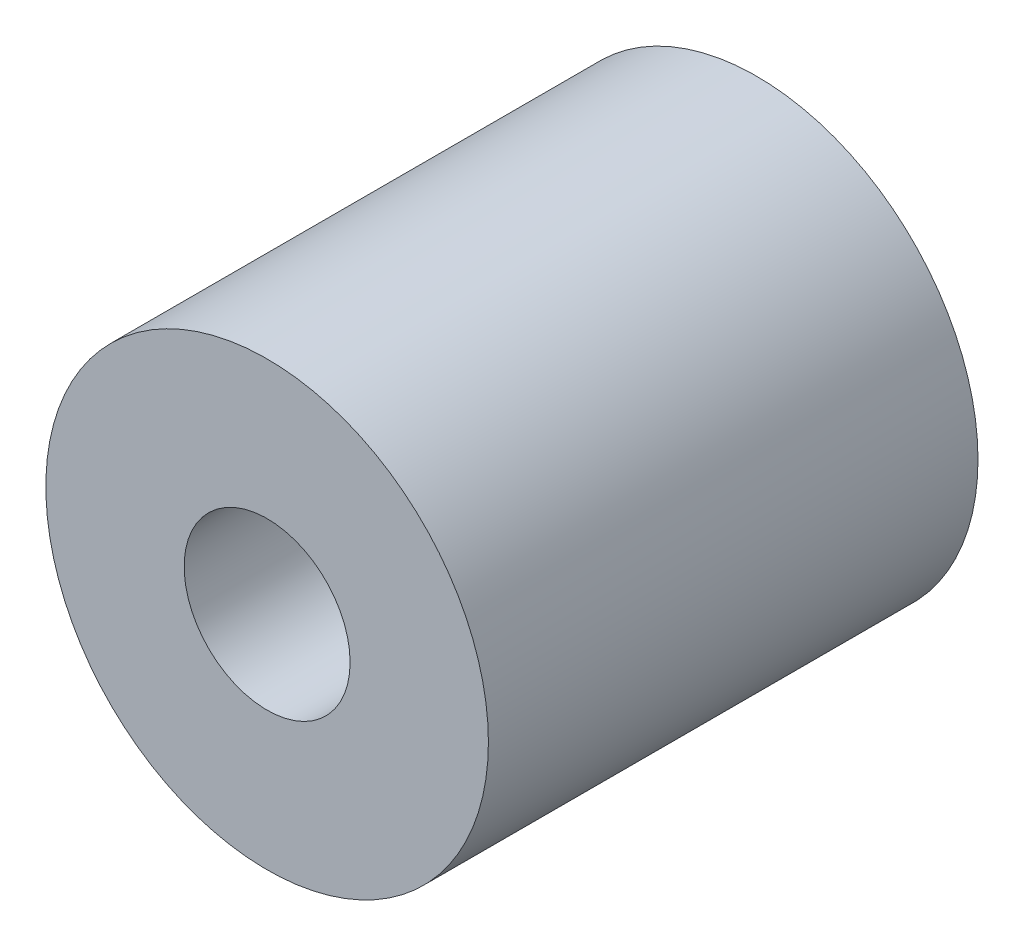
from build123d import *

# Parameters (mm, degrees)
CROQUIS1_R              = 16
CROQUIS1_R_2            = 11
SALIENTE_EXTRUIR1_DEPTH = 19
CROQUIS2_R              = 16
CROQUIS2_R_2            = 6
SALIENTE_EXTRUIR2_DEPTH = 16.4


with BuildPart() as part:
    # Croquis1 → Saliente-Extruir1 (new body)
    with BuildSketch(Plane.XY):
        Circle(CROQUIS1_R)
        Circle(CROQUIS1_R_2, mode=Mode.SUBTRACT)
    extrude(amount=SALIENTE_EXTRUIR1_DEPTH)

    # Croquis2 → Saliente-Extruir2 (add)
    with BuildSketch(Plane.XY.offset(19)):
        Circle(CROQUIS2_R)
        Circle(CROQUIS2_R_2, mode=Mode.SUBTRACT)
    extrude(amount=SALIENTE_EXTRUIR2_DEPTH)


solid = part.part
